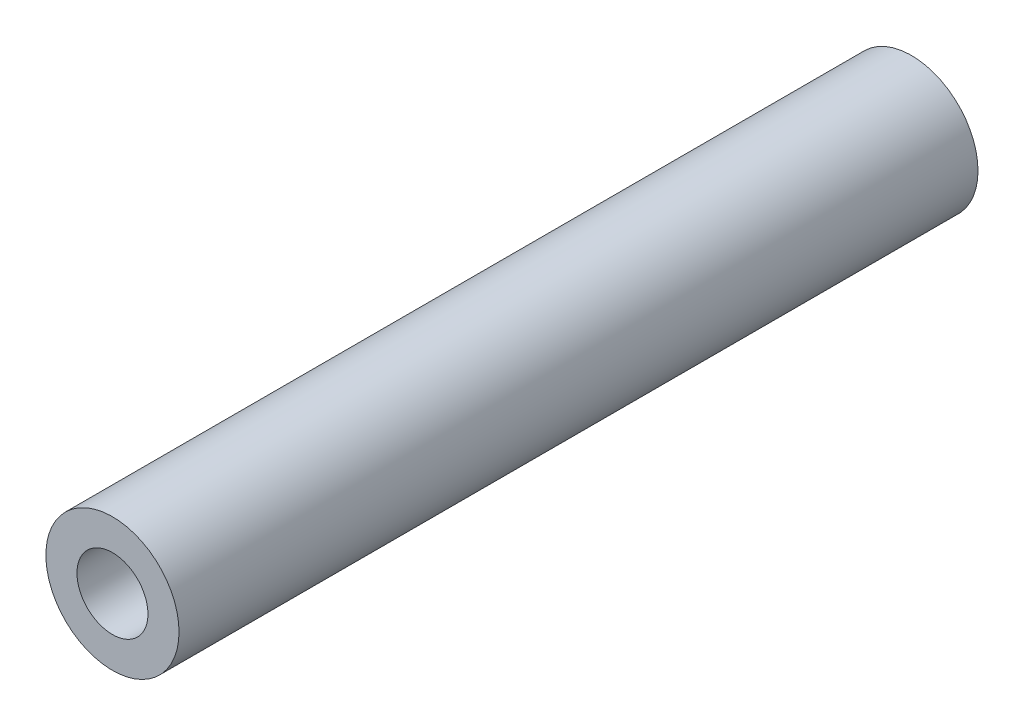
from build123d import *

# Parameters (mm, degrees)
SKETCH_1_R          = 3
EXTRUDE_1_DEPTH     = 36
SKETCH_2_R          = 1.6
CUT_EXTRUDE_1_DEPTH = 36


with BuildPart() as part:
    # ｽｹｯﾁ1 → ﾎﾞｽ - 押し出し1 (new body)
    with BuildSketch(Plane.XY):
        Circle(SKETCH_1_R)
    extrude(amount=EXTRUDE_1_DEPTH)

    # ｽｹｯﾁ2 → ｶｯﾄ - 押し出し1 (cut)
    with BuildSketch(Plane.XY.offset(36)):
        Circle(SKETCH_2_R)
    extrude(amount=-CUT_EXTRUDE_1_DEPTH, mode=Mode.SUBTRACT)


solid = part.part
